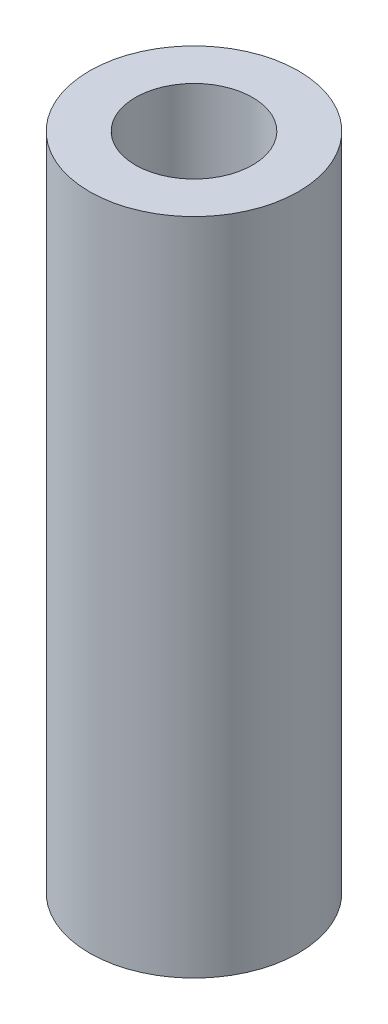
from build123d import *

# Parameters (mm, degrees)
SKETCH1_R           = 5.7785
SKETCH1_R_2         = 3.2385
BOSS_EXTRUDE1_DEPTH = 18.2245


with BuildPart() as part:
    # Sketch1 → Boss-Extrude1 (new body, symmetric)
    with BuildSketch(Plane(origin=(0, 0, 0), x_dir=(1, 0, 0), z_dir=(0, 1, 0))):
        Circle(SKETCH1_R)
        Circle(SKETCH1_R_2, mode=Mode.SUBTRACT)
    extrude(amount=BOSS_EXTRUDE1_DEPTH, both=True)


solid = part.part
